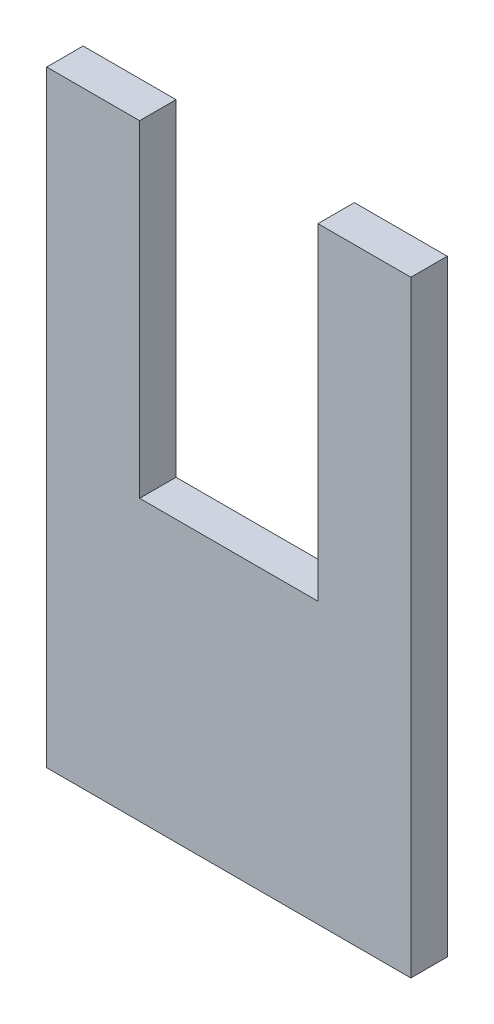
from build123d import *

# Parameters (mm, degrees)
BOSS_EXTRU_1_DEPTH = 3


with BuildPart() as part:
    # Esquisse1 → Boss.-Extru.1 (new body)
    with BuildSketch(Plane.XY):
        Polygon((-55.824183593, 43.970188902), (-48.170396409, 43.970188902), (-48.170396409, -6.029811098), (-78.170396409, -6.029811098), (-78.170396409, 43.970188902), (-70.516609226, 43.970188902), (-70.516609226, 17.025260195), (-55.824183593, 17.025260195), align=None)
    extrude(amount=BOSS_EXTRU_1_DEPTH)


solid = part.part
